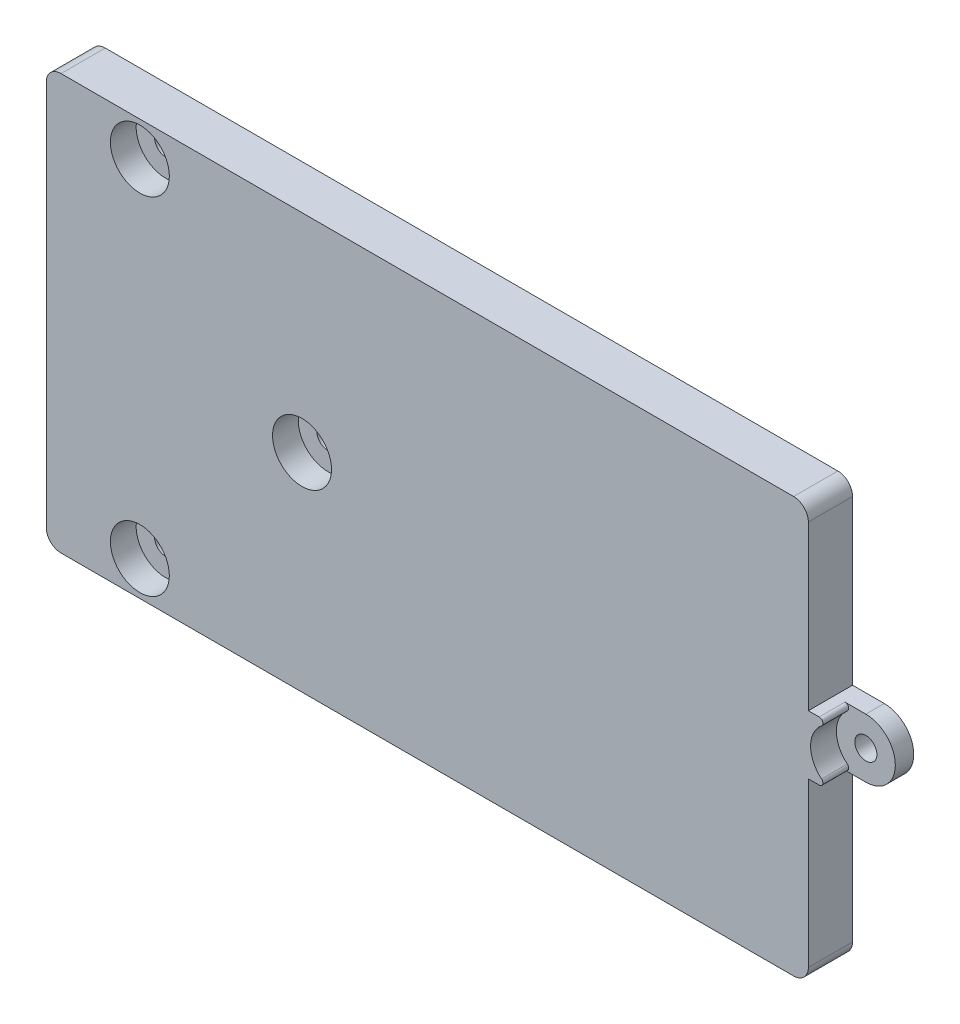
from build123d import *

# Parameters (mm, degrees)
BOSS_EXTRUDE1_DEPTH      = 1.5
BOSS_EXTRUDE1_DEPTH_BACK = 1.5
SKETCH2_R                = 0.7500000000000021
SKETCH2_R_2              = 0.7500000000000003
SKETCH2_R_3              = 0.750000000000002
CUT_EXTRUDE1_DEPTH       = 9.500000000000002
SKETCH3_R                = 1.9999999999999996
SKETCH3_R_2              = 0.7500000000000021
SKETCH3_R_3              = 2.0000000000000004
SKETCH3_R_4              = 0.7500000000000003
SKETCH3_R_5              = 2.000000000000003
SKETCH3_R_6              = 0.750000000000002
CUT_EXTRUDE2_DEPTH       = 1.75
FILLET1_R                = 0.25
CUT_EXTRUDE5_DEPTH       = 6.999999999999993
CUT_EXTRUDE6_DEPTH       = 15.000000000000004
FILLET2_R                = 1


with BuildPart() as part:
    # Sketch1 → Boss-Extrude1 (new, two sides: drawn at the far end of the back side and taken through both)
    with BuildSketch(Plane.XY.offset(-BOSS_EXTRUDE1_DEPTH_BACK)):
        with BuildLine():
            Line((-26.000000000000007, -14.235000000000003), (25.999999999999993, -14.234999999999996))
            Line((25.999999999999993, -14.234999999999996), (25.999999999999993, -2))
            Line((25.999999999999993, -2), (27.99999999999995, -2))
            ThreePointArc((27.99999999999995, -2.000000000000003), (29.999999999999996, -1.79e-15), (27.999999999999954, 2.000000000000003))
            Line((27.999999999999954, 2), (25.999999999999993, 2))
            Line((25.999999999999993, 2), (25.999999999999993, 14.235000000000003))
            Line((25.999999999999993, 14.235000000000003), (-26.000000000000007, 14.234999999999996))
            Line((-26.000000000000007, 14.234999999999996), (-26.000000000000007, -14.235000000000003))
        make_face()
    extrude(amount=BOSS_EXTRUDE1_DEPTH + BOSS_EXTRUDE1_DEPTH_BACK)

    # Sketch2 → Cut-Extrude1 (cut)
    with BuildSketch(Plane.XY.offset(1.5)):
        with Locations((-19.500000000000007, 11.735000000000005)):
            Circle(SKETCH2_R)
        with Locations((-8.500000000000004, 0)):
            Circle(SKETCH2_R_2)
        with Locations((-19.500000000000007, -11.734999999999996)):
            Circle(SKETCH2_R)
        with Locations((27.999999999999993, -4.3e-16)):
            Circle(SKETCH2_R_3)
    extrude(amount=-CUT_EXTRUDE1_DEPTH, mode=Mode.SUBTRACT)

    # Sketch3 → Cut-Extrude2 (cut)
    # profile 1 of 4: a face of its own
    with BuildSketch(Plane.XY.offset(1.5)):
        with Locations((-19.500000000000007, 11.735000000000005)):
            Circle(SKETCH3_R)
        with Locations((-19.500000000000007, 11.735000000000005)):
            Circle(SKETCH3_R_2, mode=Mode.SUBTRACT)
    # profile 2 of 4: a face of its own
    with BuildSketch(Plane.XY.offset(1.5)):
        with Locations((-8.500000000000004, 0)):
            Circle(SKETCH3_R_3)
        with Locations((-8.500000000000004, 0)):
            Circle(SKETCH3_R_4, mode=Mode.SUBTRACT)
    # profile 3 of 4: a face of its own
    with BuildSketch(Plane.XY.offset(1.5)):
        with Locations((-19.500000000000007, -11.734999999999996)):
            Circle(SKETCH3_R)
        with Locations((-19.500000000000007, -11.734999999999996)):
            Circle(SKETCH3_R_2, mode=Mode.SUBTRACT)
    # profile 4 of 4: a face of its own
    with BuildSketch(Plane.XY.offset(1.5)):
        with Locations((27.999999999999993, -4.3e-16)):
            Circle(SKETCH3_R_5)
        with Locations((27.999999999999993, -4.3e-16)):
            Circle(SKETCH3_R_6, mode=Mode.SUBTRACT)
    extrude(amount=-CUT_EXTRUDE2_DEPTH, mode=Mode.SUBTRACT)

    # Fillet1
    fillet1_edges = [part.edges().sort_by_distance(p)[0] for p in [
        (27.99999999999995, -2.0000000000000018, 0.625),
        (27.999999999999954, 2.000000000000001, 0.625),
    ]]
    fillet(fillet1_edges, radius=FILLET1_R)

    # Sketch7 → Cut-Extrude5 (cut)
    with BuildSketch(Plane.XY.offset(1.5)):
        Polygon((25.999999999999993, -14.234999999999996), (25.999999999999993, -2), (25.84999999999999, -2), (25.84999999999999, -14.084999999999996), (-25.85, -14.084999999999999), (-25.850000000000005, 14.084999999999994), (25.84999999999999, 14.085000000000003), (25.84999999999999, 2), (25.999999999999993, 2), (25.999999999999993, 14.235000000000003), (-26.000000000000007, 14.234999999999996), (-26.000000000000007, -14.235000000000003), align=None)
    extrude(amount=-CUT_EXTRUDE5_DEPTH, mode=Mode.SUBTRACT)

    # Sketch8 → Cut-Extrude6 (cut)
    with BuildSketch(Plane.ZY.offset(25.850000000000005)):
        with BuildLine():
            Line((-1.5000000000000318, 2.7495454169736466), (-1.5000000000000313, -2.7495454169736395))
            ThreePointArc((-1.5000000000000568, -2.749545416973628), (-0.8999999999999995, 3.07e-15), (-1.5000000000000577, 2.7495454169736337))
        make_face()
    extrude(amount=-CUT_EXTRUDE6_DEPTH, mode=Mode.SUBTRACT)

    # Fillet2
    fillet2_edges = [part.edges().sort_by_distance(p)[0] for p in [
        (25.849999999999987, -14.084999999999996, 0),
        (25.84999999999999, 14.085000000000003, 0),
        (-25.850000000000005, 14.084999999999994, 0),
        (-25.85, -14.085, 0),
    ]]
    fillet(fillet2_edges, radius=FILLET2_R)


solid = part.part
